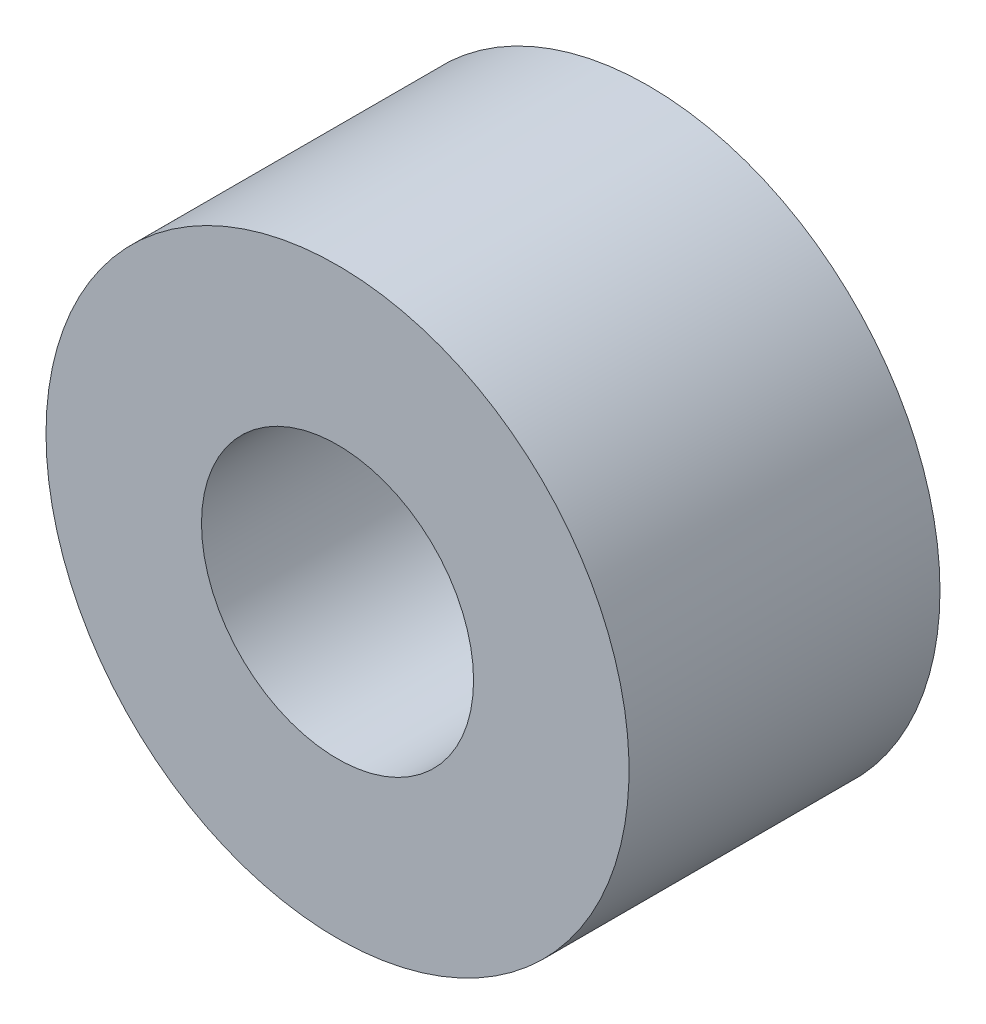
from build123d import *

# Parameters (mm, degrees)
SKETCH_1_R      = 11.25
SKETCH_1_R_2    = 5.25
EXTRUDE_1_DEPTH = 12


with BuildPart() as part:
    # Эскиз1 → Бобышка-Вытянуть1 (new body)
    with BuildSketch(Plane.XY):
        with Locations((0, 5.8)):
            Circle(SKETCH_1_R)
        with Locations((0, 5.8)):
            Circle(SKETCH_1_R_2, mode=Mode.SUBTRACT)
    extrude(amount=EXTRUDE_1_DEPTH)


solid = part.part
